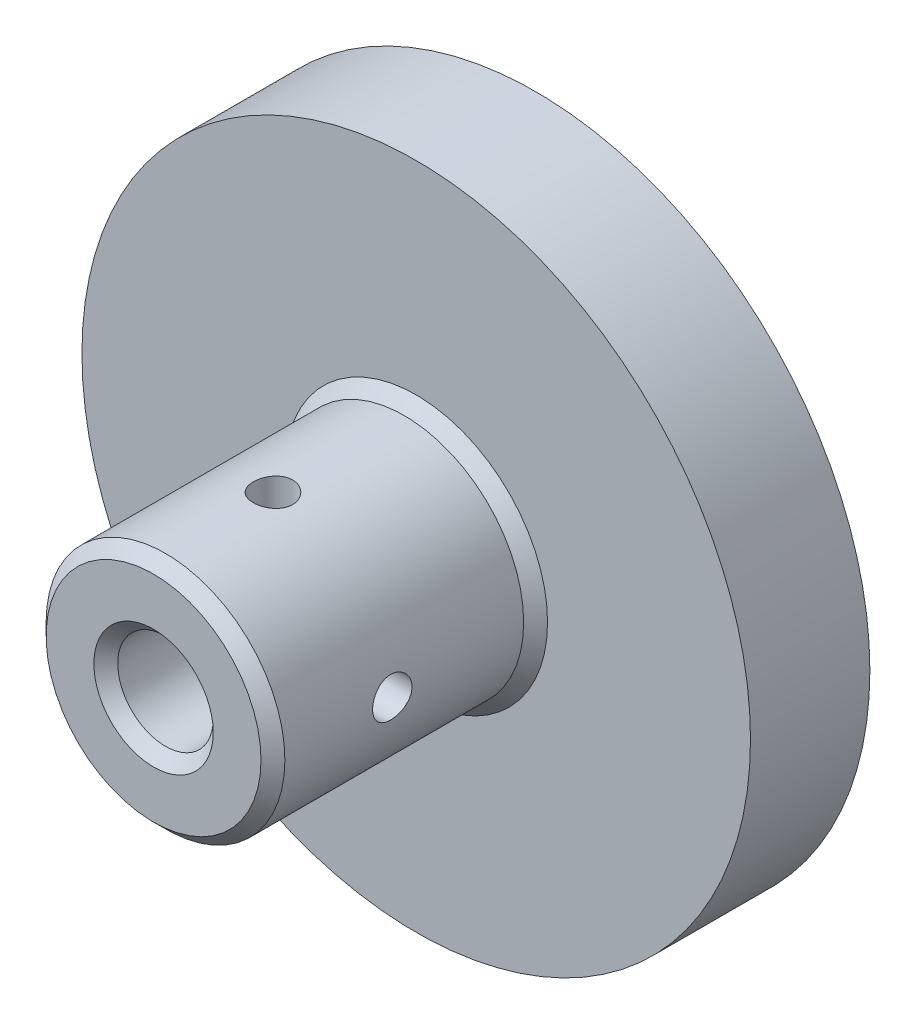
from build123d import *

# Parameters (mm, degrees)
SKETCH1_R              = 28
BOSS_EXTRUDE1_DEPTH    = 10
SKETCH2_R              = 10
BOSS_EXTRUDE2_DEPTH    = 22
SKETCH4_R              = 4
CUT_EXTRUDE2_DEPTH     = 51.911688245
CHAMFER2_SIZE          = 1
M4_TAPPED_HOLE1_REACH  = 54.077
M4_TAPPED_HOLE1_BORE_R = 1.65
CIRPATTERN2_COUNT      = 2
CIRPATTERN2_ANGLE      = 90


with BuildPart() as part:
    # Sketch1 → Boss-Extrude1 (new body)
    with BuildSketch(Plane.XY):
        Circle(SKETCH1_R)
    extrude(amount=BOSS_EXTRUDE1_DEPTH)

    # Sketch2 → Boss-Extrude2 (add)
    with BuildSketch(Plane.XY.offset(10)):
        Circle(SKETCH2_R)
    extrude(amount=BOSS_EXTRUDE2_DEPTH)

    # Sketch4 → Cut-Extrude2 (cut, through all)
    with BuildSketch(Plane.XY.offset(32)):
        Circle(SKETCH4_R)
    extrude(amount=-CUT_EXTRUDE2_DEPTH, mode=Mode.SUBTRACT)

    # Chamfer2
    chamfer2_edges = [part.edges().sort_by_distance(p)[0] for p in [
        (-4, 0, 32),
        (-10, 0, 10),
        (-10, 0, 32),
    ]]
    chamfer(chamfer2_edges, length=CHAMFER2_SIZE)

    # M4 Tapped Hole1 bore (on position points) → M4 Tapped Hole1 (cut, up to next)
    with BuildSketch(Plane(origin=(0, 10, 22), x_dir=(1, 0, 0), z_dir=(0, 1, 0)), mode=Mode.PRIVATE) as m4_tapped_hole1_sk1:
        Circle(M4_TAPPED_HOLE1_BORE_R)
    m4_tapped_hole1_tool1 = extrude(m4_tapped_hole1_sk1.sketch, amount=-M4_TAPPED_HOLE1_REACH, mode=Mode.PRIVATE) & part.part
    m4_tapped_hole1 = m4_tapped_hole1_tool1.solids().sort_by_distance((0, 10, 22))[0]
    add(m4_tapped_hole1, mode=Mode.SUBTRACT)

    # CirPattern2: M4 Tapped Hole1 ×2 about axis
    cirpattern2_axis = Axis((0, 0, 32), (0, 0, -1))
    for i in range(1, CIRPATTERN2_COUNT):
        add(m4_tapped_hole1.rotate(cirpattern2_axis, i * CIRPATTERN2_ANGLE / (CIRPATTERN2_COUNT - 1)), mode=Mode.SUBTRACT)


solid = part.part
